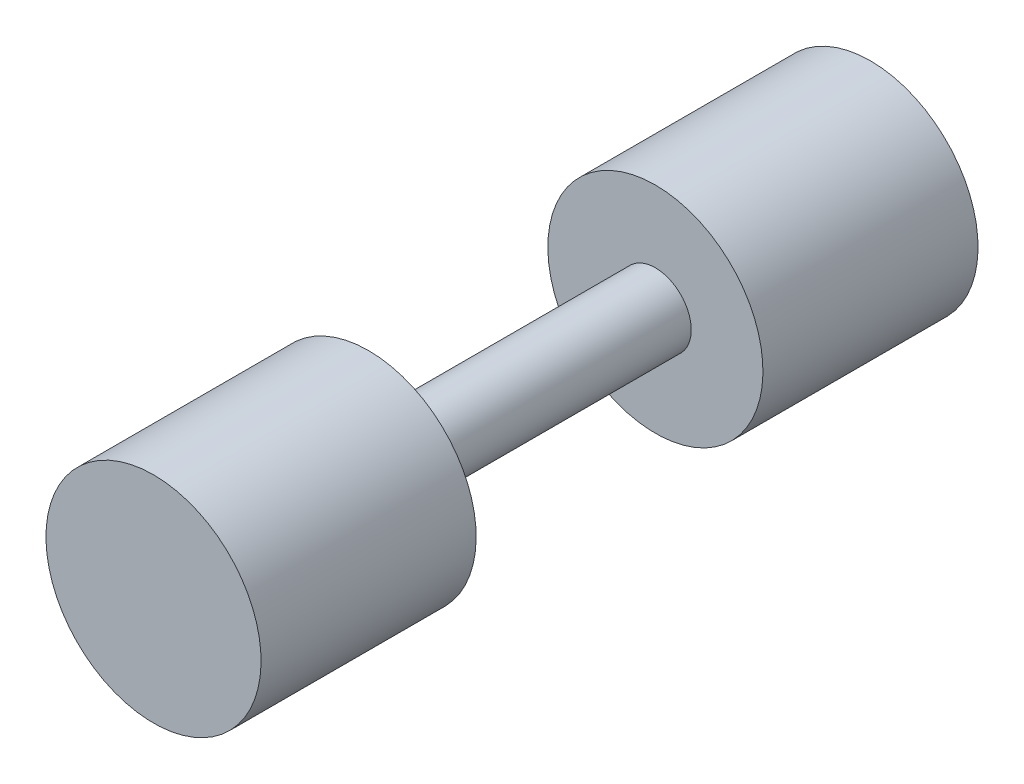
from build123d import *


with BuildPart() as part:
    # Sketch1 → Revolve1 (revolve)
    with BuildSketch(Plane(origin=(0, 0, 0), x_dir=(0, 0, -1), z_dir=(1, 0, 0))):
        Polygon((63.5, 0), (-63.5, 0), (-63.5, 19.05), (-25.4, 19.05), (-25.4, 6.35), (25.4, 6.35), (25.4, 19.05), (63.5, 19.05), align=None)
    revolve(axis=Axis((0, 0, -63.5), (0, 0, 1)))


solid = part.part
